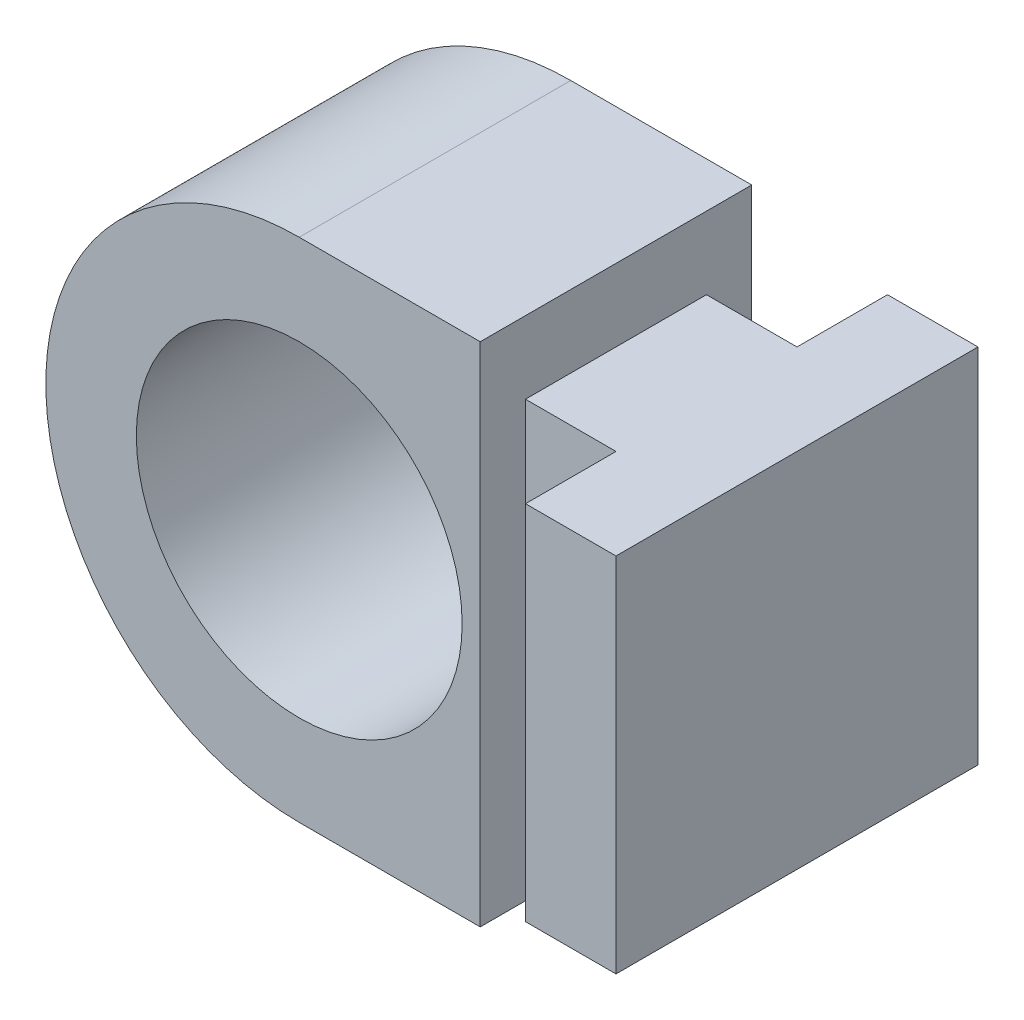
from build123d import *

# Parameters (mm, degrees)
ESQUISSE1_R        = 9
BOSS_EXTRU_1_DEPTH = 7.5
BOSS_EXTRU_2_START = -4
BOSS_EXTRU_2_DEPTH = 20


with BuildPart() as part:
    # Esquisse1 → Boss.-Extru.1 (new body, symmetric)
    with BuildSketch(Plane.XY):
        with BuildLine():
            Line((0, 14), (10, 14))
            Line((10, 14), (10, -14))
            Line((10, -14), (0, -14))
            ThreePointArc((0, -14), (-14, 0), (0, 14))
        make_face()
        Circle(ESQUISSE1_R, mode=Mode.SUBTRACT)
    extrude(amount=BOSS_EXTRU_1_DEPTH, both=True)


with BuildPart() as body_2:
    # Esquisse2 → Boss.-Extru.2 (new body)
    with BuildSketch(Plane(origin=(0, 14, 0), x_dir=(1, 0, 0), z_dir=(0, 1, 0)).offset(BOSS_EXTRU_2_START)):
        Polygon((10, 5), (15, 5), (15, 10), (20, 10), (20, -10), (15, -10), (15, -5), (10, -5), align=None)
    extrude(amount=-BOSS_EXTRU_2_DEPTH)


solid = Compound([part.part, body_2.part])
